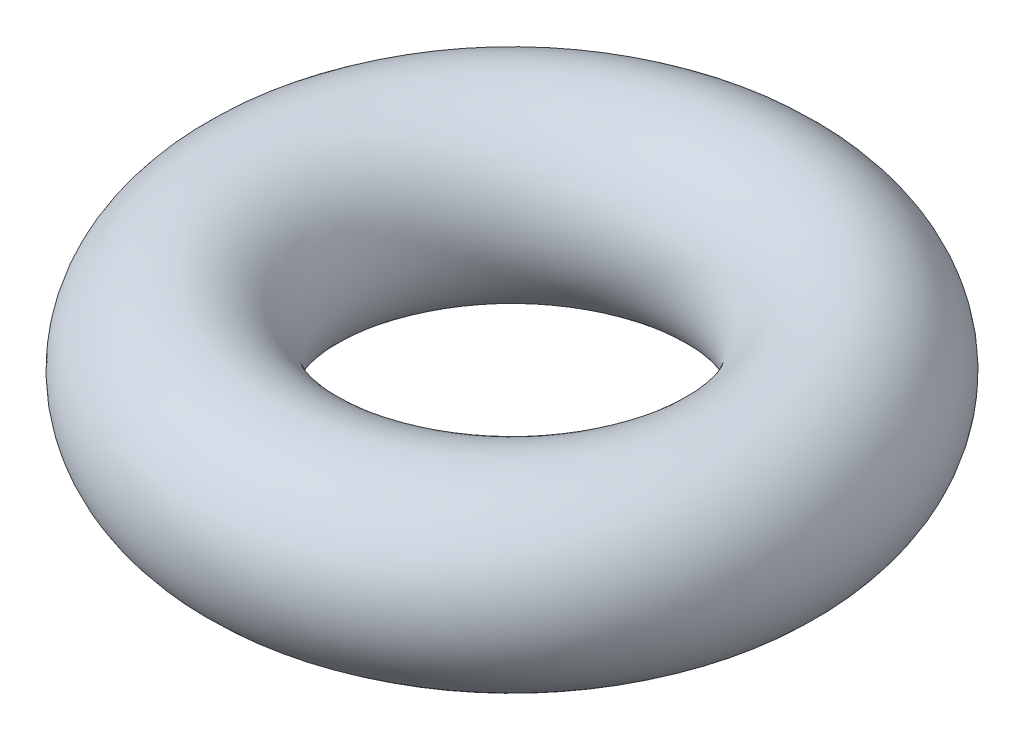
from build123d import *

# Parameters (mm, degrees)
SKETCH2_R = 0.889


with BuildPart() as part:
    # Sketch2 → Revolve1 (revolve)
    with BuildSketch(Plane.XY):
        with Locations((-2.3368, 0)):
            Circle(SKETCH2_R)
    revolve(axis=Axis((0, 0, 0), (0, 1, 0)))


solid = part.part
